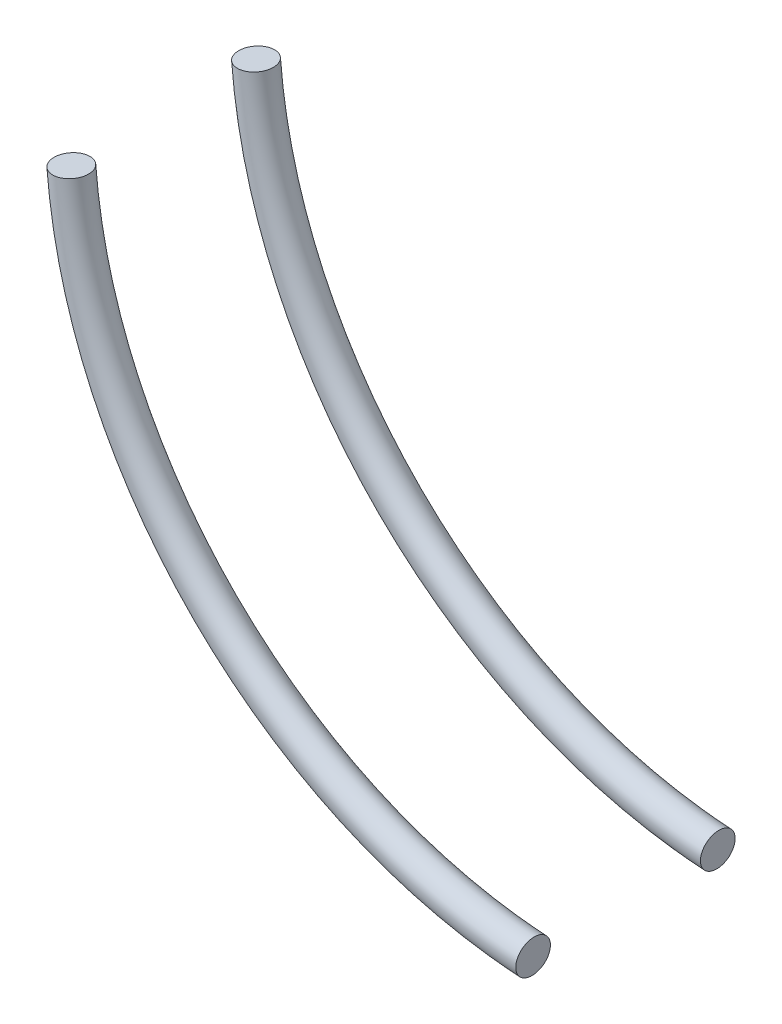
from build123d import *

# Parameters (mm, degrees)
SKETCH_2_R = 0.75


with BuildPart() as part:
    # 掃出1: sweep along a path in 草圖1
    with BuildLine(Plane.XY) as sweep_1_path:
        ThreePointArc((0, 20), (6.328444531, 6.436996791), (20, 0.346607863))
    # 草圖2 → 掃出1 (sweep)
    with BuildSketch(Plane(origin=(0, 20, 0), x_dir=(-0.996881157, -0.078917412, 0), z_dir=(0.078917412, -0.996881157, 0))):
        with Locations((0, 4)):
            Circle(SKETCH_2_R)
        with Locations((0, -4)):
            Circle(SKETCH_2_R)
    sweep(path=sweep_1_path.line)


solid = part.part
